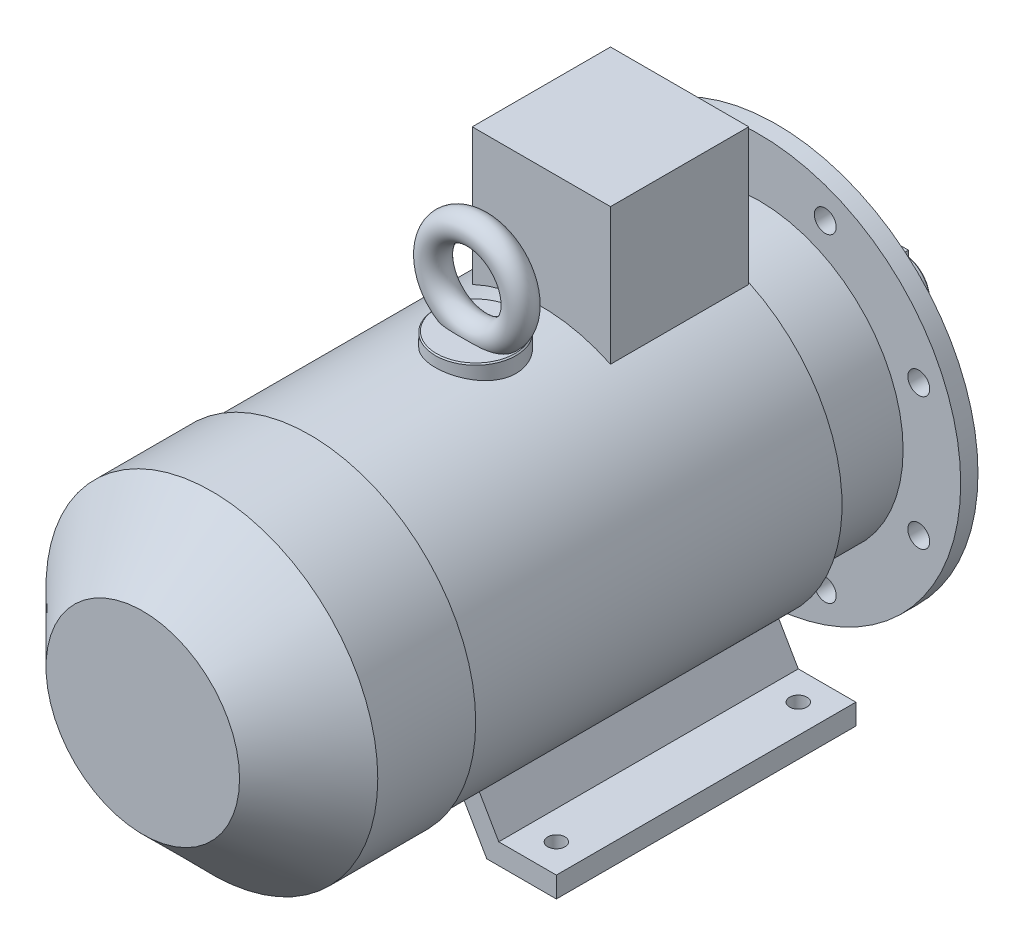
from build123d import *

# Parameters (mm, degrees)
SKETCH_1_R           = 24
EXTRUDE_1_DEPTH      = 110
SKETCH_2_W           = 9
SKETCH_2_H           = 9
EXTRUDE_2_DEPTH      = 0.1
EXTRUDE_2_DEPTH_BACK = 55
SKETCH_3_R           = 175
EXTRUDE_3_DEPTH      = 15
SKETCH_4_R           = 125
SKETCH_4_R_2         = 116
EXTRUDE_4_DEPTH      = 5
SKETCH_5_R           = 116
SKETCH_5_R_2         = 40
CUT_EXTRUDE_1_DEPTH  = 8
CHAMFER_1_SIZE       = 1
SKETCH_6_R           = 9.5
CUT_EXTRUDE_2_DEPTH  = 16
SKETCH_7_R           = 125
EXTRUDE_5_DEPTH      = 68
SKETCH_8_R           = 140
EXTRUDE_6_DEPTH      = 322
SKETCH_9_R           = 144
EXTRUDE_7_DEPTH      = 145
CHAMFER_2_SIZE       = 60
EXTRUDE_8_DEPTH      = 260
CUT_EXTRUDE_3_REACH  = 337
SKETCH_11_R          = 7.5
SKETCH_12_W          = 120
SKETCH_12_H          = 120
EXTRUDE_9_DEPTH      = 245
SKETCH_13_R          = 35
EXTRUDE_10_DEPTH     = 150
CHAMFER_3_SIZE       = 1
SKETCH_15_R          = 12
SKETCH_16_R          = 16
EXTRUDE_11_DEPTH     = 14
EXTRUDE_12_DEPTH     = 16
SKETCH_18_R          = 7
CUT_EXTRUDE_4_DEPTH  = 16


with BuildPart() as part:
    # Эскиз1 → Вытянуть1 (new body)
    with BuildSketch(Plane.XY):
        Circle(SKETCH_1_R)
    extrude(amount=EXTRUDE_1_DEPTH)

    # Эскиз2 → Вытянуть2 (add, two sides)
    with BuildSketch(Plane(origin=(0, 0, 0), x_dir=(-1, 0, 0), z_dir=(0, 0, -1))) as extrude_2_sk:
        with Locations((0, 23)):
            Rectangle(SKETCH_2_W, SKETCH_2_H)
    extrude(amount=EXTRUDE_2_DEPTH)
    extrude(extrude_2_sk.sketch, amount=-EXTRUDE_2_DEPTH_BACK)

    # Эскиз3 → Вытянуть3 (add)
    with BuildSketch(Plane.XY.offset(110)):
        Circle(SKETCH_3_R)
    extrude(amount=EXTRUDE_3_DEPTH)

    # Эскиз4 → Вытянуть4 (add)
    with BuildSketch(Plane(origin=(0, 0, 110), x_dir=(-1, 0, 0), z_dir=(0, 0, -1))):
        with Locations(Location((0, 0, 0), (0, 0, 180))):  # turned: the seam where the file's is
            Circle(SKETCH_4_R)
        Circle(SKETCH_4_R_2, mode=Mode.SUBTRACT)
    extrude(amount=EXTRUDE_4_DEPTH)

    # Эскиз5 → Вырез-Вытянуть1 (cut)
    with BuildSketch(Plane(origin=(0, 0, 110), x_dir=(-1, 0, 0), z_dir=(0, 0, -1))):
        Circle(SKETCH_5_R)
        Circle(SKETCH_5_R_2, mode=Mode.SUBTRACT)
    extrude(amount=-CUT_EXTRUDE_1_DEPTH, mode=Mode.SUBTRACT)

    # Фаска1
    chamfer_1_edges = [part.edges().sort_by_distance(p)[0] for p in [
        (-125, 0, 105),
        (40, 0, 110),
        (-15.297058541, -18.493242009, 0),
    ]]
    chamfer(chamfer_1_edges, length=CHAMFER_1_SIZE)

    # Эскиз6 → Вырез-Вытянуть2 (cut, through all)
    with BuildSketch(Plane(origin=(0, 0, 110), x_dir=(-1, 0, 0), z_dir=(0, 0, -1))):
        with Locations((-57.402514855, 138.581929877)):
            Circle(SKETCH_6_R)
        with Locations((57.402514855, 138.581929877)):
            Circle(SKETCH_6_R)
        with Locations((138.581929877, 57.402514855)):
            Circle(SKETCH_6_R)
        with Locations((138.581929877, -57.402514855)):
            Circle(SKETCH_6_R)
        with Locations((57.402514855, -138.581929877)):
            Circle(SKETCH_6_R)
        with Locations((-57.402514855, -138.581929877)):
            Circle(SKETCH_6_R)
        with Locations((-138.581929877, -57.402514855)):
            Circle(SKETCH_6_R)
        with Locations((-138.581929877, 57.402514855)):
            Circle(SKETCH_6_R)
    extrude(amount=-CUT_EXTRUDE_2_DEPTH, mode=Mode.SUBTRACT)

    # Эскиз7 → Вытянуть5 (add)
    with BuildSketch(Plane.XY.offset(125)):
        Circle(SKETCH_7_R)
    extrude(amount=EXTRUDE_5_DEPTH)

    # Эскиз8 → Вытянуть6 (add)
    with BuildSketch(Plane.XY.offset(193)):
        Circle(SKETCH_8_R)
    extrude(amount=EXTRUDE_6_DEPTH)

    # Эскиз9 → Вытянуть7 (add)
    with BuildSketch(Plane.XY.offset(515)):
        Circle(SKETCH_9_R)
    extrude(amount=EXTRUDE_7_DEPTH)

    # Фаска2
    chamfer_2_edges = [part.edges().sort_by_distance(p)[0] for p in [
        (-144, 0, 660),
    ]]
    chamfer(chamfer_2_edges, length=CHAMFER_2_SIZE)

    # Эскиз10 → Вытянуть8 (add)
    with BuildSketch(Plane(origin=(0, 0, 193), x_dir=(-1, 0, 0), z_dir=(0, 0, -1))):
        Polygon((-152, -160), (-91.607695155, -160), (-51.945448858, -91.302974272), (-67.533906126, -82.302974272), (-102, -142), (-152, -142), align=None)
        Polygon((91.607695155, -160), (51.945448858, -91.302974272), (67.533906126, -82.302974272), (102, -142), (152, -142), (152, -160), align=None)
    extrude(amount=-EXTRUDE_8_DEPTH)

    # Эскиз11 → Вырез-Вытянуть3 (cut, up to next)
    with BuildSketch(Plane.XZ.offset(160), mode=Mode.PRIVATE) as cut_extrude_3_sk1:
        with Locations((-127, 218)):
            Circle(SKETCH_11_R)
    cut_extrude_3_tool1 = extrude(cut_extrude_3_sk1.sketch, amount=-CUT_EXTRUDE_3_REACH, mode=Mode.PRIVATE) & part.part
    add(cut_extrude_3_tool1.solids().sort_by_distance((-127, -160, 218))[0], mode=Mode.SUBTRACT)
    # Эскиз11 → Вырез-Вытянуть3 (cut, up to next)
    with BuildSketch(Plane.XZ.offset(160), mode=Mode.PRIVATE) as cut_extrude_3_sk2:
        with Locations((127, 218)):
            Circle(SKETCH_11_R)
    cut_extrude_3_tool2 = extrude(cut_extrude_3_sk2.sketch, amount=-CUT_EXTRUDE_3_REACH, mode=Mode.PRIVATE) & part.part
    add(cut_extrude_3_tool2.solids().sort_by_distance((127, -160, 218))[0], mode=Mode.SUBTRACT)
    # Эскиз11 → Вырез-Вытянуть3 (cut, up to next)
    with BuildSketch(Plane.XZ.offset(160), mode=Mode.PRIVATE) as cut_extrude_3_sk3:
        with Locations((-127, 428)):
            Circle(SKETCH_11_R)
    cut_extrude_3_tool3 = extrude(cut_extrude_3_sk3.sketch, amount=-CUT_EXTRUDE_3_REACH, mode=Mode.PRIVATE) & part.part
    add(cut_extrude_3_tool3.solids().sort_by_distance((-127, -160, 428))[0], mode=Mode.SUBTRACT)
    # Эскиз11 → Вырез-Вытянуть3 (cut, up to next)
    with BuildSketch(Plane.XZ.offset(160), mode=Mode.PRIVATE) as cut_extrude_3_sk4:
        with Locations((127, 428)):
            Circle(SKETCH_11_R)
    cut_extrude_3_tool4 = extrude(cut_extrude_3_sk4.sketch, amount=-CUT_EXTRUDE_3_REACH, mode=Mode.PRIVATE) & part.part
    add(cut_extrude_3_tool4.solids().sort_by_distance((127, -160, 428))[0], mode=Mode.SUBTRACT)

    # Эскиз12 → Вытянуть9 (add)
    with BuildSketch(Plane(origin=(0, 0, 0), x_dir=(1, 0, 0), z_dir=(0, 1, 0))):
        with Locations((0, -254)):
            Rectangle(SKETCH_12_W, SKETCH_12_H)
    extrude(amount=EXTRUDE_9_DEPTH)

    # Эскиз13 → Вытянуть10 (add)
    with BuildSketch(Plane(origin=(0, 0, 0), x_dir=(1, 0, 0), z_dir=(0, 1, 0))):
        with Locations(Location((0, -371, 0), (0, 0, 90))):  # turned: the seam where the file's is
            Circle(SKETCH_13_R)
    extrude(amount=EXTRUDE_10_DEPTH)

    # Фаска3
    chamfer_3_edges = [part.edges().sort_by_distance(p)[0] for p in [
        (0, 150, 406),
    ]]
    chamfer(chamfer_3_edges, length=CHAMFER_3_SIZE)

    # По траектории1: sweep along a path in Эскиз14
    with BuildLine(Plane.XY.offset(370)) as sweep_1_path:
        CenterArc((0, 188), 38, 0, 360)
    # Эскиз15 → По траектории1 (sweep)
    with BuildSketch(Plane(origin=(0, 0, 0), x_dir=(0, 0, -1), z_dir=(1, 0, 0))):
        with Locations((-370, 226)):
            Circle(SKETCH_15_R)
    sweep(path=sweep_1_path.line)

    # Эскиз16 → Вытянуть11 (add)
    with BuildSketch(Plane.ZY.offset(60)):
        with Locations(Location((254, 185, 0), (0, 0, 180))):  # turned: the seam where the file's is
            Circle(SKETCH_16_R)
    extrude(amount=EXTRUDE_11_DEPTH)

    # Эскиз17 → Вытянуть12 (add)
    with BuildSketch(Plane.ZY.offset(74)):
        Polygon((254, 207.516660498), (234.5, 196.258330249), (234.5, 173.741669751), (254, 162.483339502), (273.5, 173.741669751), (273.5, 196.258330249), align=None)
    extrude(amount=EXTRUDE_12_DEPTH)

    # Эскиз18 → Вырез-Вытянуть4 (cut)
    with BuildSketch(Plane.ZY.offset(90)):
        with Locations((254, 185)):
            Circle(SKETCH_18_R)
    extrude(amount=-CUT_EXTRUDE_4_DEPTH, mode=Mode.SUBTRACT)


solid = part.part
